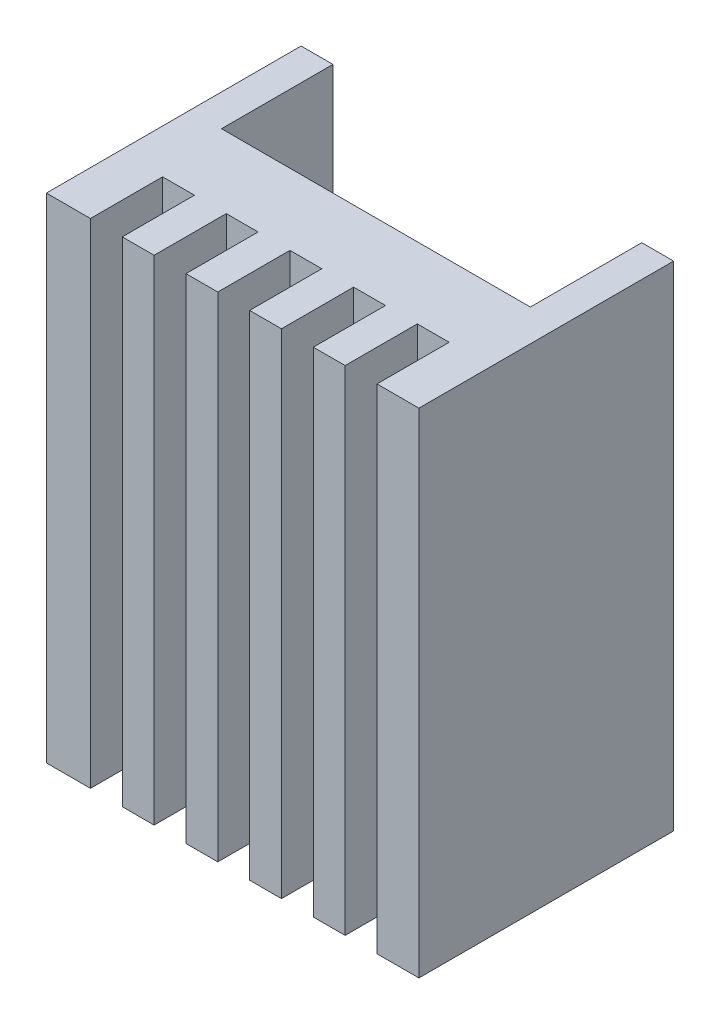
from build123d import *

# Parameters (mm, degrees)
BOSS_EXTRUDE1_DEPTH = 31
SKETCH2_W           = 2
SKETCH2_H           = 4.533544861
CUT_EXTRUDE1_DEPTH  = 32


with BuildPart() as part:
    # Sketch1 → Boss-Extrude1 (new body)
    with BuildSketch(Plane(origin=(0, 0, 0), x_dir=(1, 0, 0), z_dir=(0, 1, 0))):
        Polygon((21.4, 16), (23.4, 16), (23.4, 0), (0, 0), (0, 16), (2, 16), (2, 9), (21.4, 9), align=None)
    extrude(amount=BOSS_EXTRUDE1_DEPTH)

    # Sketch2 → Cut-Extrude1 (cut, through all)
    with BuildSketch(Plane(origin=(0, 31, 0), x_dir=(1, 0, 0), z_dir=(0, 1, 0))):
        with Locations((3.766668881, 2.266772431)):
            Rectangle(SKETCH2_W, SKETCH2_H)
        with Locations((7.766668881, 2.266772431)):
            Rectangle(SKETCH2_W, SKETCH2_H)
        with Locations((11.766668881, 2.266772431)):
            Rectangle(SKETCH2_W, SKETCH2_H)
        with Locations((15.766668881, 2.266772431)):
            Rectangle(SKETCH2_W, SKETCH2_H)
        with Locations((19.766668881, 2.266772431)):
            Rectangle(SKETCH2_W, SKETCH2_H)
    extrude(amount=-CUT_EXTRUDE1_DEPTH, mode=Mode.SUBTRACT)


solid = part.part
